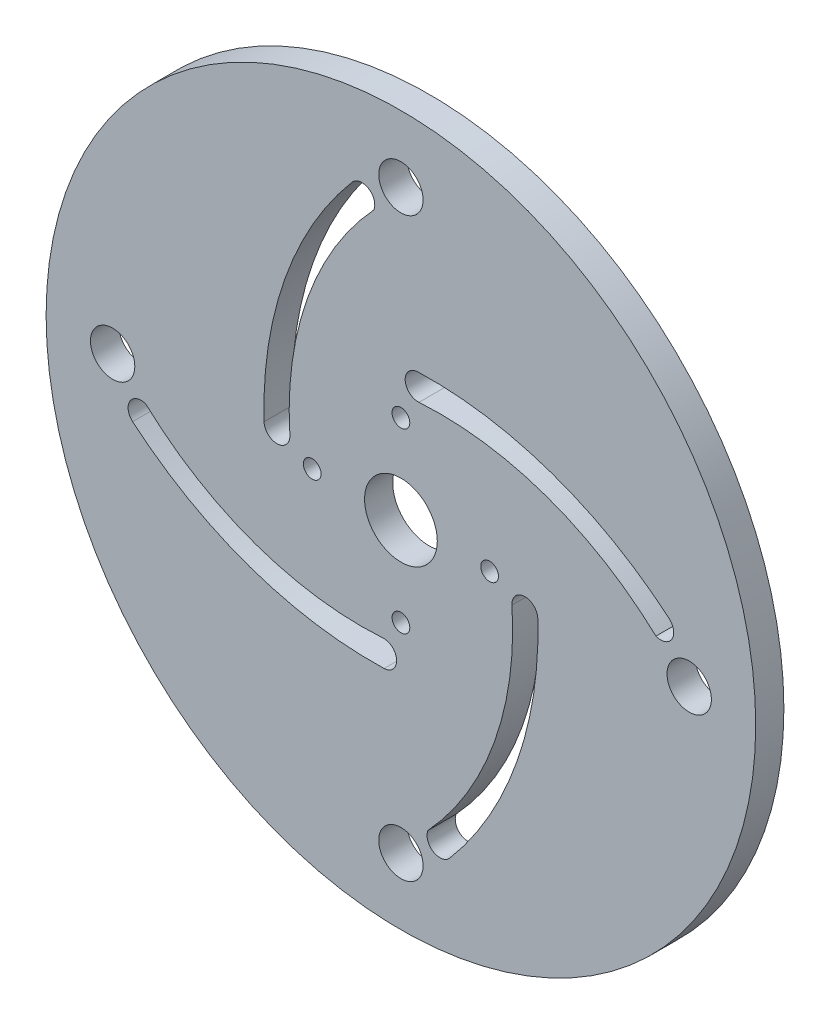
from build123d import *

# Parameters (mm, degrees)
SKETCH1_R           = 40
SKETCH1_R_2         = 4.1
SKETCH1_R_3         = 1
SKETCH1_R_4         = 2.5
BOSS_EXTRUDE1_DEPTH = 3.175


with BuildPart() as part:
    # Sketch1 → Boss-Extrude1 (new body)
    with BuildSketch(Plane.XY):
        Circle(SKETCH1_R)
        Circle(SKETCH1_R_2, mode=Mode.SUBTRACT)
        with Locations((10, 0)):
            Circle(SKETCH1_R_3, mode=Mode.SUBTRACT)
        with Locations((0, -10)):
            Circle(SKETCH1_R_3, mode=Mode.SUBTRACT)
        with Locations((-10, 0)):
            Circle(SKETCH1_R_3, mode=Mode.SUBTRACT)
        with Locations((0, 10)):
            Circle(SKETCH1_R_3, mode=Mode.SUBTRACT)
        with Locations((0, 32.500000024)):
            Circle(SKETCH1_R_4, mode=Mode.SUBTRACT)
        with Locations((32.500000024, 0)):
            Circle(SKETCH1_R_4, mode=Mode.SUBTRACT)
        with Locations((0, -32.500000024)):
            Circle(SKETCH1_R_4, mode=Mode.SUBTRACT)
        with Locations((-32.500000024, 0)):
            Circle(SKETCH1_R_4, mode=Mode.SUBTRACT)
        with BuildLine():
            ThreePointArc((1.892882879, 15.429065651), (16.987986018, 13.094493375), (30.244053834, 5.505749571))
            ThreePointArc((30.244053834, 5.505749571), (30.545302534, 3.644891179), (28.754168977, 3.057196265))
            ThreePointArc((28.754168977, 3.057196265), (16.369486394, 10.54396404), (2.033129259, 12.519038334))
            ThreePointArc((2.033129259, 12.519038334), (0.481040246, 13.902629865), (1.892882879, 15.429065651))
        make_face(mode=Mode.SUBTRACT)
        with BuildLine():
            ThreePointArc((15.429065651, -1.892882879), (13.094493375, -16.987986018), (5.505749571, -30.244053834))
            ThreePointArc((5.505749571, -30.244053834), (3.644891179, -30.545302534), (3.057196265, -28.754168977))
            ThreePointArc((3.057196265, -28.754168977), (10.54396404, -16.369486394), (12.519038334, -2.033129259))
            ThreePointArc((12.519038334, -2.033129259), (13.902629865, -0.481040246), (15.429065651, -1.892882879))
        make_face(mode=Mode.SUBTRACT)
        with BuildLine():
            ThreePointArc((-1.892882879, -15.429065651), (-16.987986018, -13.094493375), (-30.244053834, -5.505749571))
            ThreePointArc((-30.244053834, -5.505749571), (-30.545302534, -3.644891179), (-28.754168977, -3.057196265))
            ThreePointArc((-28.754168977, -3.057196265), (-16.369486394, -10.54396404), (-2.033129259, -12.519038334))
            ThreePointArc((-2.033129259, -12.519038334), (-0.481040246, -13.902629865), (-1.892882879, -15.429065651))
        make_face(mode=Mode.SUBTRACT)
        with BuildLine():
            ThreePointArc((-15.429065651, 1.892882879), (-13.094493375, 16.987986018), (-5.505749571, 30.244053834))
            ThreePointArc((-5.505749571, 30.244053834), (-3.644891179, 30.545302534), (-3.057196265, 28.754168977))
            ThreePointArc((-3.057196265, 28.754168977), (-10.54396404, 16.369486394), (-12.519038334, 2.033129259))
            ThreePointArc((-12.519038334, 2.033129259), (-13.902629865, 0.481040246), (-15.429065651, 1.892882879))
        make_face(mode=Mode.SUBTRACT)
    extrude(amount=BOSS_EXTRUDE1_DEPTH)


solid = part.part
